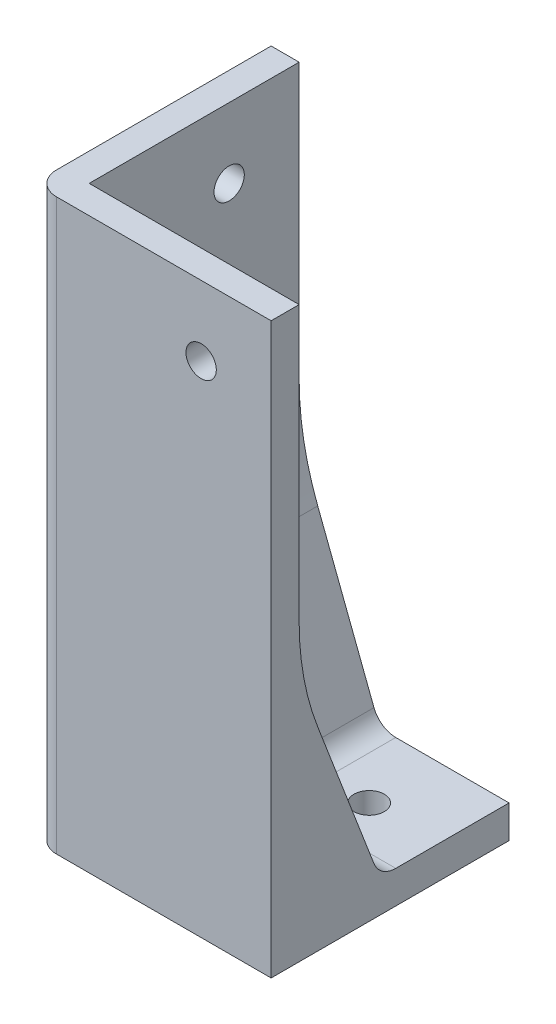
from build123d import *
from OCP.BRepFilletAPI import BRepFilletAPI_MakeChamfer

# Parameters (mm, degrees)
SKETCH2_W                      = 51
SKETCH2_H                      = 51
SKETCH2_R                      = 3.25
BOSS_EXTRUDE2_DEPTH            = 7
BOSS_EXTRUDE3_DEPTH            = 115
F_6_5_6_5_DIAMETER_HOLE1_D     = 6.5
F_6_5_6_5_DIAMETER_HOLE1_DEPTH = 6
F_6_5_6_5_DIAMETER_HOLE1_TIP   = 1.952797012
F_6_5_6_5_DIAMETER_HOLE2_D     = 6.5
F_6_5_6_5_DIAMETER_HOLE2_DEPTH = 6
F_6_5_6_5_DIAMETER_HOLE2_TIP   = 1.952797012
CHAMFER1_SIZE                  = 45
CHAMFER1_SIZE2                 = 17.273881577
FILLET1_R                      = 5
FILLET2_R                      = 60
FILLET3_R                      = 5


with BuildPart() as part:
    # Sketch2 → Boss-Extrude2 (new body)
    with BuildSketch(Plane(origin=(0, 0, 0), x_dir=(1, 0, 0), z_dir=(0, 1, 0))):
        with Locations((25.5, 25.5)):
            Rectangle(SKETCH2_W, SKETCH2_H)
        with Locations(Location((36, 36, 0), (0, 0, 270))):
            Circle(SKETCH2_R, mode=Mode.SUBTRACT)
    extrude(amount=BOSS_EXTRUDE2_DEPTH)

    # Sketch3 → Boss-Extrude3 (add)
    with BuildSketch(Plane(origin=(0, 7, 0), x_dir=(1, 0, 0), z_dir=(0, 1, 0))):
        Polygon((51, 0), (0, 0), (0, 51), (6, 51), (6, 6), (51, 6), align=None)
    extrude(amount=BOSS_EXTRUDE3_DEPTH)

    # Ø6.5 (6.5) Diameter Hole1
    with Locations(Plane.XY):
        with Locations((36, 107)):
            Hole(F_6_5_6_5_DIAMETER_HOLE1_D / 2, depth=F_6_5_6_5_DIAMETER_HOLE1_DEPTH)
            with Locations((0, 0, -(F_6_5_6_5_DIAMETER_HOLE1_DEPTH + F_6_5_6_5_DIAMETER_HOLE1_TIP / 2))):  # 118° drill point
                Cone(0, F_6_5_6_5_DIAMETER_HOLE1_D / 2, F_6_5_6_5_DIAMETER_HOLE1_TIP, mode=Mode.SUBTRACT)

    # Ø6.5 (6.5) Diameter Hole2
    with Locations(Plane.ZY):
        with Locations((-36, 107)):
            Hole(F_6_5_6_5_DIAMETER_HOLE2_D / 2, depth=F_6_5_6_5_DIAMETER_HOLE2_DEPTH)
            with Locations((0, 0, -(F_6_5_6_5_DIAMETER_HOLE2_DEPTH + F_6_5_6_5_DIAMETER_HOLE2_TIP / 2))):  # 118° drill point
                Cone(0, F_6_5_6_5_DIAMETER_HOLE2_D / 2, F_6_5_6_5_DIAMETER_HOLE2_TIP, mode=Mode.SUBTRACT)

    # Chamfer1: one chamfer whose edges measure the first distance from different faces: ONE call of the kernel's chamfer builder (chamfer() names one face for all edges)
    chamfer1_edges_1 = [part.edges().sort_by_distance(p)[0] for p in [
        (28.5, 7, -6),
    ]]
    chamfer1_side_1 = [part.faces().sort_by_distance(p)[0] for p in [
        (28.451598229, 64.2257233, -6),
    ]]
    chamfer1_edges_2 = [part.edges().sort_by_distance(p)[0] for p in [
        (6, 7, -28.5),
    ]]
    chamfer1_side_2 = [part.faces().sort_by_distance(p)[0] for p in [
        (6, 64.2257233, -28.451598229),
    ]]
    chamfer1 = BRepFilletAPI_MakeChamfer(part.part.solid().wrapped)
    for e in chamfer1_edges_1:
        chamfer1.Add(CHAMFER1_SIZE, CHAMFER1_SIZE2, e.wrapped, chamfer1_side_1[0].wrapped)  # the first distance lies on this face
    for e in chamfer1_edges_2:
        chamfer1.Add(CHAMFER1_SIZE, CHAMFER1_SIZE2, e.wrapped, chamfer1_side_2[0].wrapped)  # the first distance lies on this face
    add(Compound.cast(chamfer1.Shape()), mode=Mode.REPLACE)

    # Fillet1
    fillet1_edges = [part.edges().sort_by_distance(p)[0] for p in [
        (0, 61, 0),
    ]]
    fillet(fillet1_edges, radius=FILLET1_R)

    # Fillet2
    fillet2_edges = [part.edges().sort_by_distance(p)[0] for p in [
        (28.5, 52, -6),
        (6, 52, -28.5),
    ]]
    fillet(fillet2_edges, radius=FILLET2_R)

    # Fillet3
    fillet3_edges = [part.edges().sort_by_distance(p)[0] for p in [
        (23.273881577, 7, -37.136940788),
        (37.136940788, 7, -23.273881577),
    ]]
    fillet(fillet3_edges, radius=FILLET3_R)


solid = part.part
